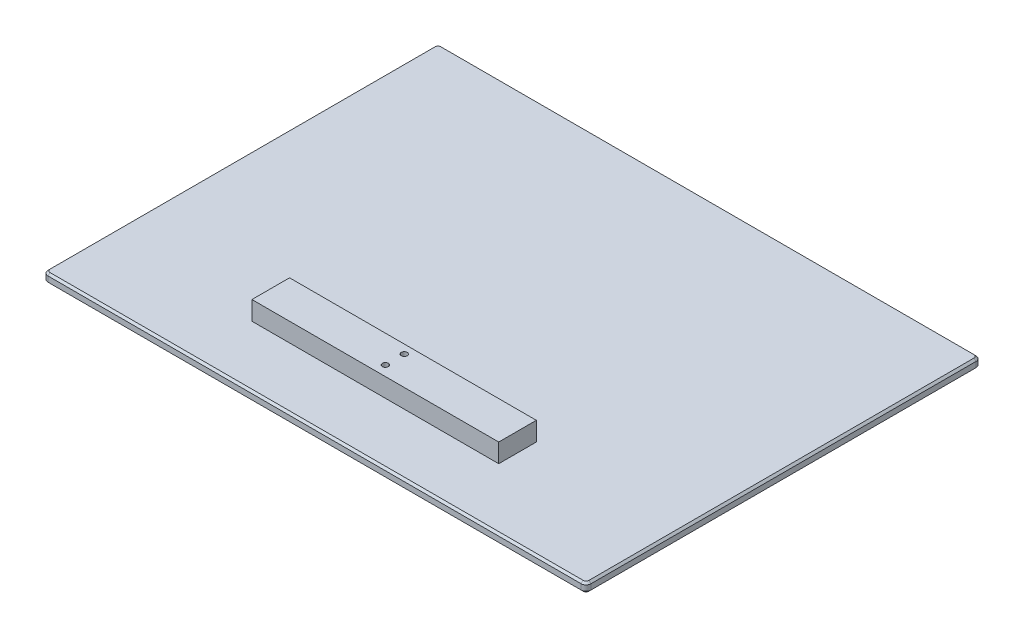
from build123d import *

# Parameters (mm, degrees)
SKETCH1_W           = 550
SKETCH1_H           = 400
BOSS_EXTRUDE1_DEPTH = 9.525
FILLET2_R           = 5
CHAMFER1_SIZE       = 2
CHAMFER2_SIZE       = 2
SKETCH3_W           = 250
SKETCH3_H           = 38.1
SKETCH3_R           = 3
BOSS_EXTRUDE2_DEPTH = 19.05


with BuildPart() as part:
    # Sketch1 → Boss-Extrude1 (new body)
    with BuildSketch(Plane(origin=(0, 0, 0), x_dir=(1, 0, 0), z_dir=(0, 1, 0))):
        Rectangle(SKETCH1_W, SKETCH1_H)
    extrude(amount=BOSS_EXTRUDE1_DEPTH)

    # Fillet2
    fillet2_edges = [part.edges().sort_by_distance(p)[0] for p in [
        (275, 4.7625, 200),
        (-275, 4.7625, 200),
        (-275, 4.7625, -200),
        (275, 4.7625, -200),
    ]]
    fillet(fillet2_edges, radius=FILLET2_R)

    # Chamfer1
    chamfer1_edges = [part.edges().sort_by_distance(p)[0] for p in [
        (-275, 9.525, 0),
        (0, 9.525, -200),
        (275, 9.525, 0),
        (0, 9.525, 200),
        (-273.535533906, 9.525, 198.535533906),
        (273.535533906, 9.525, 198.535533906),
        (273.535533906, 9.525, -198.535533906),
        (-273.535533906, 9.525, -198.535533906),
    ]]
    chamfer(chamfer1_edges, length=CHAMFER1_SIZE)

    # Chamfer2
    chamfer2_edges = [part.edges().sort_by_distance(p)[0] for p in [
        (-275, 0, 0),
        (275, 0, 0),
        (0, 0, 200),
        (0, 0, -200),
        (-273.535533906, 0, 198.535533906),
        (273.535533906, 0, 198.535533906),
        (273.535533906, 0, -198.535533906),
        (-273.535533906, 0, -198.535533906),
    ]]
    chamfer(chamfer2_edges, length=CHAMFER2_SIZE)

    # Sketch3 → Boss-Extrude2 (add)
    with BuildSketch(Plane(origin=(0, 9.525, 0), x_dir=(1, 0, 0), z_dir=(0, 1, 0))):
        with Locations((0, -119.4)):
            Rectangle(SKETCH3_W, SKETCH3_H)
        with Locations((0, -109.15)):
            Circle(SKETCH3_R, mode=Mode.SUBTRACT)
        with Locations((0, -128.25)):
            Circle(SKETCH3_R, mode=Mode.SUBTRACT)
    extrude(amount=BOSS_EXTRUDE2_DEPTH)


solid = part.part
